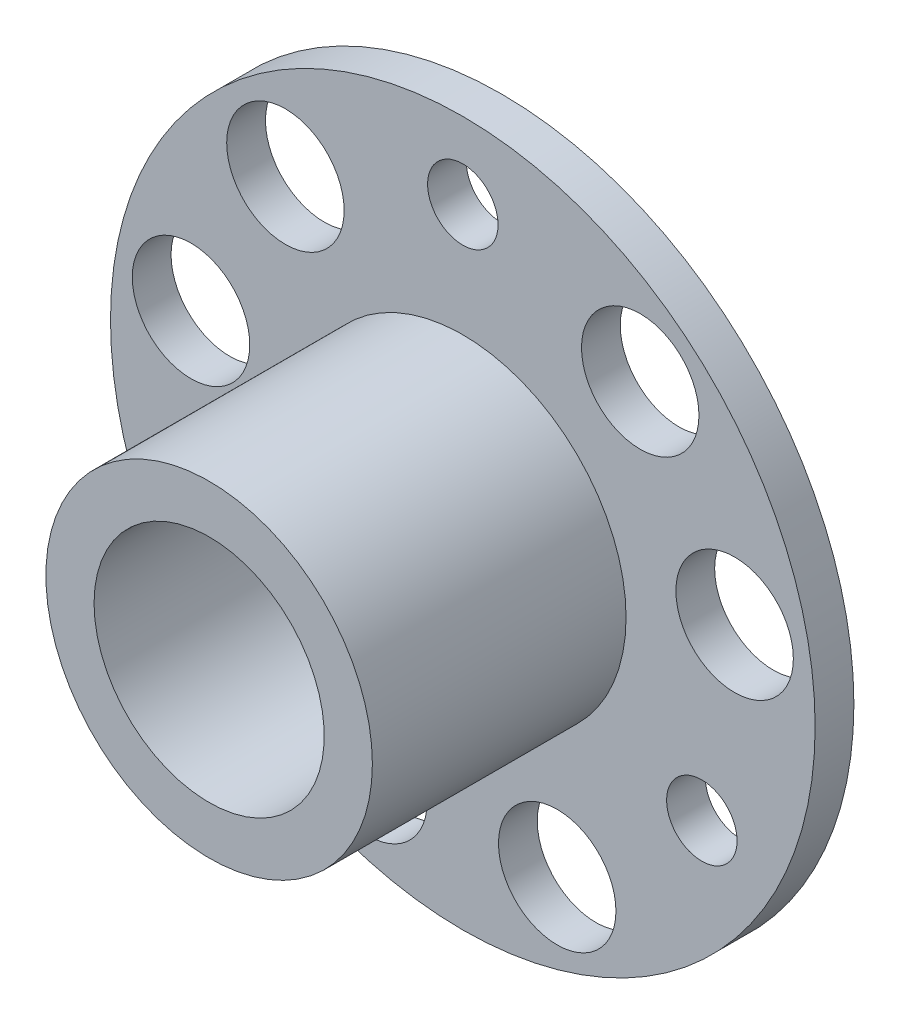
from build123d import *

# Parameters (mm, degrees)
SKETCH1_W                      = 15
SKETCH1_H                      = 1.65
SKETCH2_R                      = 6.95
BOSS_EXTRUDE1_DEPTH            = 10.8
F_5_0_5_DIAMETER_HOLE1_D       = 5
F_5_0_5_DIAMETER_HOLE1_DEPTH   = 12.45
F_3_0_3_DIAMETER_HOLE1_D       = 3
F_3_0_3_DIAMETER_HOLE1_DEPTH   = 12.45
F_9_8_9_8_DIAMETER_HOLE1_D     = 9.8
F_9_8_9_8_DIAMETER_HOLE1_DEPTH = 12.45
FILLET1_R                      = 0.5


with BuildPart() as part:
    # Sketch1 → Revolve1 (revolve)
    with BuildSketch(Plane(origin=(0, 0, 0), x_dir=(1, 0, 0), z_dir=(0, 1, 0))):
        with Locations((7.5, -0.825)):
            Rectangle(SKETCH1_W, SKETCH1_H)
    revolve(axis=Axis((0, 0, 0), (0, 0, 1)))

    # Sketch2 → Boss-Extrude1 (add)
    with BuildSketch(Plane.XY.offset(1.65)):
        Circle(SKETCH2_R)
    extrude(amount=BOSS_EXTRUDE1_DEPTH)

    # Ø5.0 (5) Diameter Hole1
    with Locations(Plane(origin=(0, 0, 0), x_dir=(-1, 0, 0), z_dir=(0, 0, -1))):
        with Locations((7.552754414, 9.001022207), (11.571491098, 2.040366088), (4.018736684, -11.041388294), (-4.018736684, -11.041388294), (-11.571491098, 2.040366088), (-7.552754414, 9.001022207)):
            Hole(F_5_0_5_DIAMETER_HOLE1_D / 2, depth=F_5_0_5_DIAMETER_HOLE1_DEPTH)

    # Ø3.0 (3) Diameter Hole1
    with Locations(Plane(origin=(0, 0, 0), x_dir=(-1, 0, 0), z_dir=(0, 0, -1))):
        with Locations((0, 11.75), (10.175798494, -5.875), (-10.175798494, -5.875)):
            Hole(F_3_0_3_DIAMETER_HOLE1_D / 2, depth=F_3_0_3_DIAMETER_HOLE1_DEPTH)

    # Ø9.8 (9.8) Diameter Hole1
    with Locations(Plane(origin=(0, 0, 0), x_dir=(-1, 0, 0), z_dir=(0, 0, -1))):
        with Locations((0, 0)):
            Hole(F_9_8_9_8_DIAMETER_HOLE1_D / 2, depth=F_9_8_9_8_DIAMETER_HOLE1_DEPTH)

    # Fillet1
    fillet1_edges = [part.edges().sort_by_distance(p)[0] for p in [
        (-4.9, 0, 0),
    ]]
    fillet(fillet1_edges, radius=FILLET1_R)


solid = part.part
